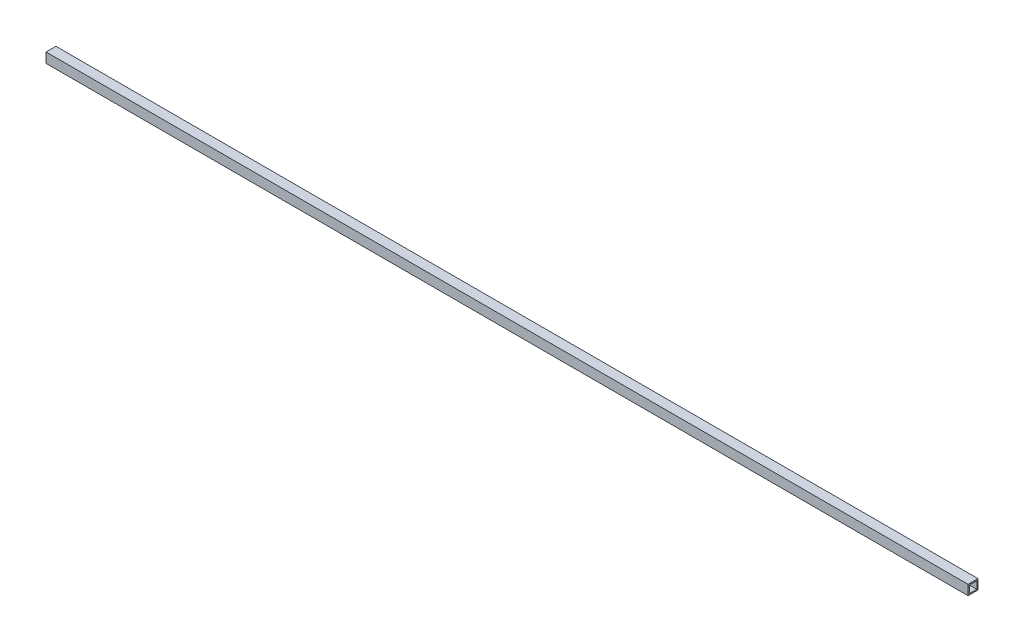
from build123d import *

# Parameters (mm, degrees)
SKETCH1_W           = 50.8
SKETCH1_H           = 50.8
SKETCH1_W_2         = 38.1
SKETCH1_H_2         = 38.1
BOSS_EXTRUDE1_DEPTH = 4736.465


with BuildPart() as part:
    # Sketch1 → Boss-Extrude1 (new body)
    with BuildSketch(Plane(origin=(0, 0, 0), x_dir=(0, 0, -1), z_dir=(1, 0, 0))):
        Rectangle(SKETCH1_W, SKETCH1_H)
        Rectangle(SKETCH1_W_2, SKETCH1_H_2, mode=Mode.SUBTRACT)
    extrude(amount=BOSS_EXTRUDE1_DEPTH)


solid = part.part
